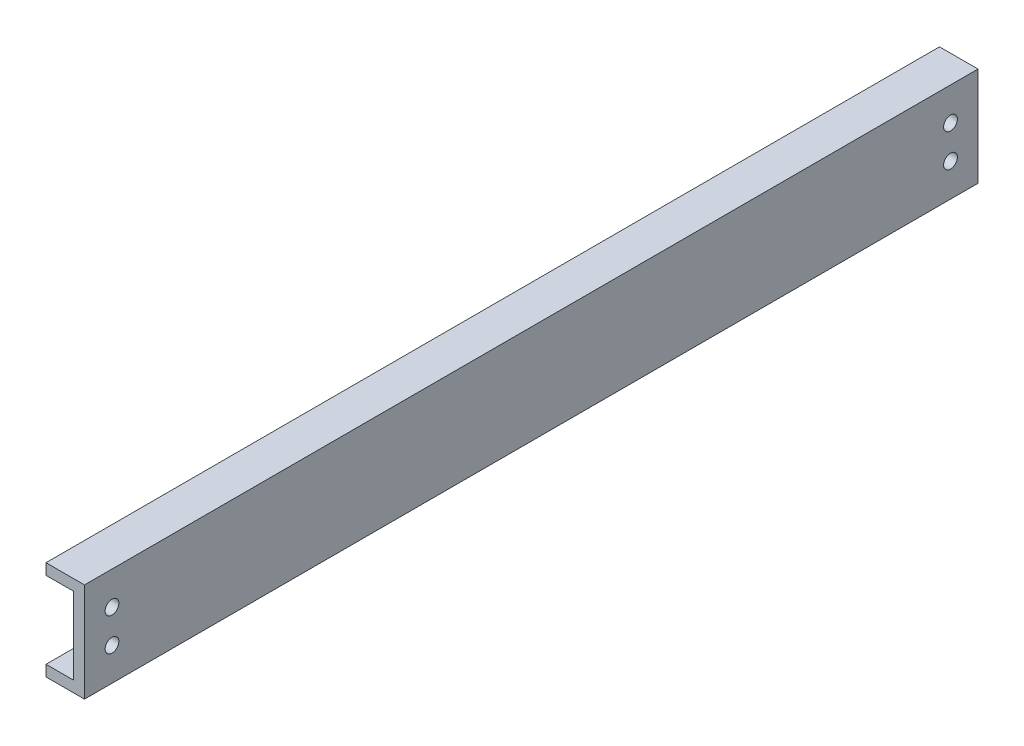
from build123d import *

# Parameters (mm, degrees)
BOSS_EXTRUDE1_DEPTH = 162.5
SKETCH2_R           = 1.25
CUT_EXTRUDE1_DEPTH  = 8
SKETCH3_R           = 1.25
CUT_EXTRUDE2_DEPTH  = 10


with BuildPart() as part:
    # Sketch1 → Boss-Extrude1 (new body)
    with BuildSketch(Plane.XY):
        Polygon((-7, 9.888282785), (0, 9.888282785), (0, -8.111717215), (-7, -8.111717215), (-7, -6.111717215), (-2, -6.111717215), (-2, 7.888282785), (-7, 7.888282785), align=None)
    extrude(amount=-BOSS_EXTRUDE1_DEPTH)

    # Sketch2 → Cut-Extrude1 (cut, through all)
    with BuildSketch(Plane(origin=(0, 0, 0), x_dir=(0, 0, -1), z_dir=(1, 0, 0))):
        with Locations((5, 3.888282785)):
            Circle(SKETCH2_R)
        with Locations((5, -2.111717215)):
            Circle(SKETCH2_R)
        with Locations((157.5, -2.111717215)):
            Circle(SKETCH2_R)
        with Locations((157.5, 3.888282785)):
            Circle(SKETCH2_R)
    extrude(amount=-CUT_EXTRUDE1_DEPTH, mode=Mode.SUBTRACT)

    # Sketch3 → Cut-Extrude2 (cut)
    with BuildSketch(Plane.XZ.offset(8.111717215)):
        with Locations((-4.5, -37)):
            Circle(SKETCH3_R)
        with Locations((-4.5, -43)):
            Circle(SKETCH3_R)
        with Locations((-4.5, -112)):
            Circle(SKETCH3_R)
        with Locations((-4.5, -118)):
            Circle(SKETCH3_R)
    extrude(amount=-CUT_EXTRUDE2_DEPTH, mode=Mode.SUBTRACT)


solid = part.part
